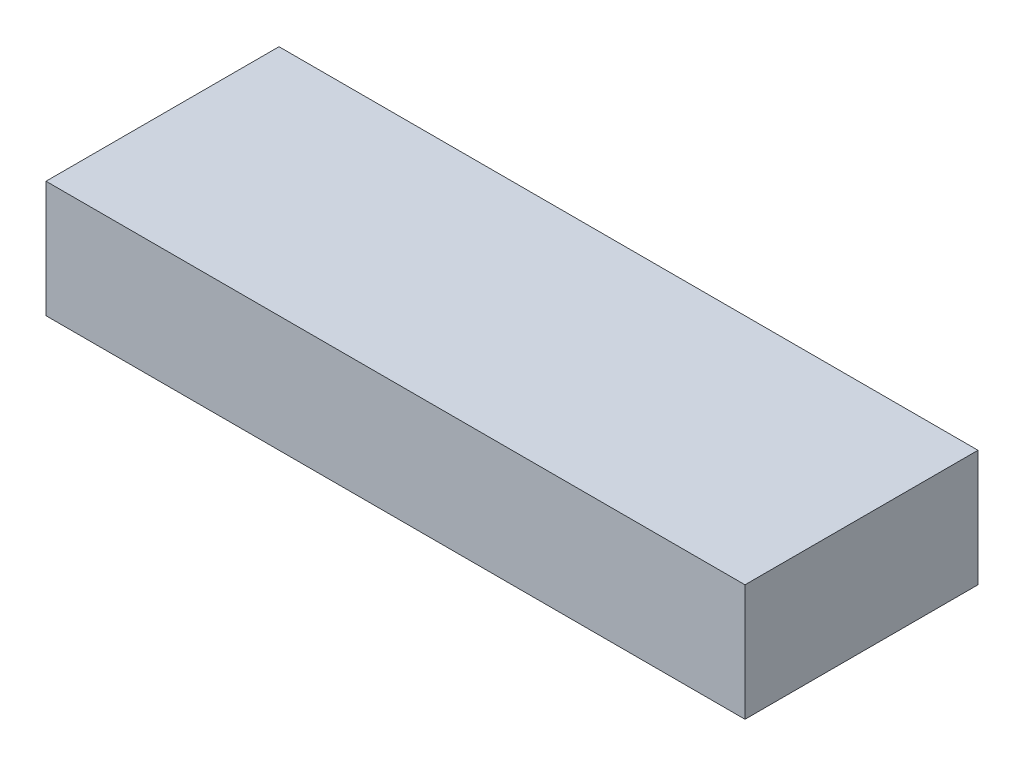
from build123d import *

# Parameters (mm, degrees)
SKETCH1_W           = 38.1
SKETCH1_H           = 12.7
BOSS_EXTRUDE1_DEPTH = 3.175


with BuildPart() as part:
    # Sketch1 → Boss-Extrude1 (new body, symmetric)
    with BuildSketch(Plane(origin=(0, 0, 0), x_dir=(1, 0, 0), z_dir=(0, 1, 0))):
        Rectangle(SKETCH1_W, SKETCH1_H)
    extrude(amount=BOSS_EXTRUDE1_DEPTH, both=True)


solid = part.part
